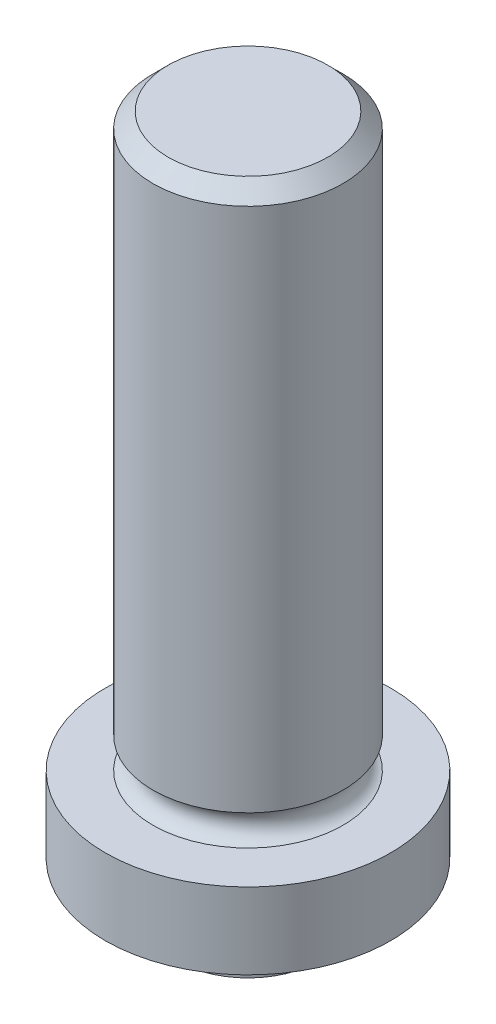
from build123d import *

# Parameters (mm, degrees)
FILLET1_R     = 0.127
CHAMFER1_SIZE = 0.508


with BuildPart() as part:
    # Sketch1 → Revolve1 (revolve)
    with BuildSketch(Plane.XY):
        with BuildLine():
            Line((0, 23.368), (3.17119, 23.368))
            Line((3.17119, 23.368), (3.17119, 5.334))
            ThreePointArc((3.17119, 5.334), (2.774555586, 4.826), (3.17119, 4.318))
            Line((3.17119, 4.318), (4.7625, 4.318))
            Line((4.7625, 4.318), (4.7625, 1.778))
            Line((4.7625, 1.778), (2.3749, 1.778))
            Line((2.3749, 1.778), (2.3749, 0))
            Line((2.3749, 0), (0, 0))
            Line((0, 0), (0, 23.368))
        make_face()
    revolve(axis=Axis((0, 0, 0), (0, 1, 0)))

    # Fillet1
    fillet1_edges = [part.edges().sort_by_distance(p)[0] for p in [
        (-2.3749, 1.778, 0),
    ]]
    fillet(fillet1_edges, radius=FILLET1_R)

    # Chamfer1
    chamfer1_edges = [part.edges().sort_by_distance(p)[0] for p in [
        (-3.17119, 23.368, 0),
    ]]
    chamfer(chamfer1_edges, length=CHAMFER1_SIZE)


solid = part.part
